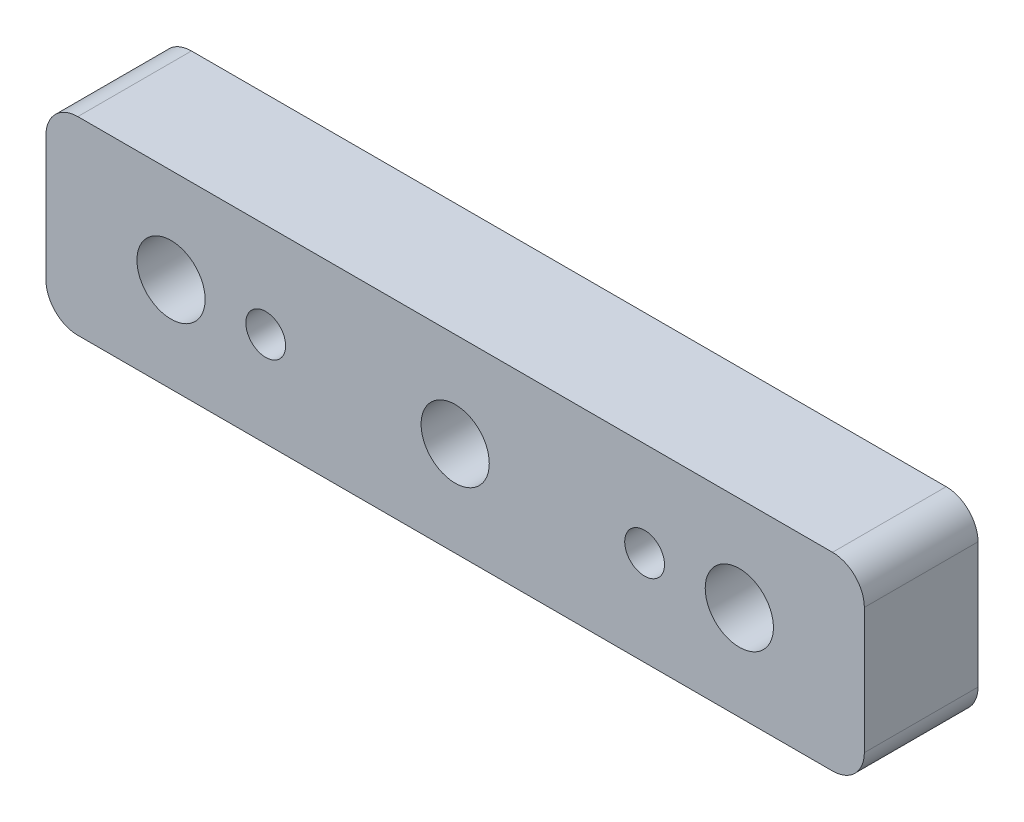
from build123d import *

# Parameters (mm, degrees)
BOSS_EXTRUDE1_DEPTH   = 12
SKETCH3_R             = 3.6
CUT_EXTRUDE2_DEPTH    = 13
M5X0_8_TAPPED_HOLE1_D = 4.2


with BuildPart() as part:
    # Sketch1 → Boss-Extrude1 (new body)
    with BuildSketch(Plane.XY):
        with BuildLine():
            Line((39.84, -10), (-39.84, -10))
            ThreePointArc((-39.84, -10), (-42.215878785, -9.015878785), (-43.2, -6.64))
            Line((-43.2, -6.64), (-43.2, 6.64))
            ThreePointArc((-43.2, 6.64), (-42.215878785, 9.015878785), (-39.84, 10))
            Line((-39.84, 10), (39.84, 10))
            ThreePointArc((39.84, 10), (42.215878785, 9.015878785), (43.2, 6.64))
            Line((43.2, 6.64), (43.2, -6.64))
            ThreePointArc((43.2, -6.64), (42.215878785, -9.015878785), (39.84, -10))
        make_face()
    extrude(amount=BOSS_EXTRUDE1_DEPTH)

    # Sketch3 → Cut-Extrude2 (cut, through all)
    with BuildSketch(Plane.XY.offset(12)):
        with Locations((-30, 0)):
            Circle(SKETCH3_R)
        with Locations((30, 0)):
            Circle(SKETCH3_R)
        Circle(SKETCH3_R)
    extrude(amount=-CUT_EXTRUDE2_DEPTH, mode=Mode.SUBTRACT)

    # M5x0.8 Tapped Hole1 (through all)
    with Locations(Plane.XY.offset(12)):
        with Locations((-20, 0), (20, 0)):
            Hole(M5X0_8_TAPPED_HOLE1_D / 2)


solid = part.part
